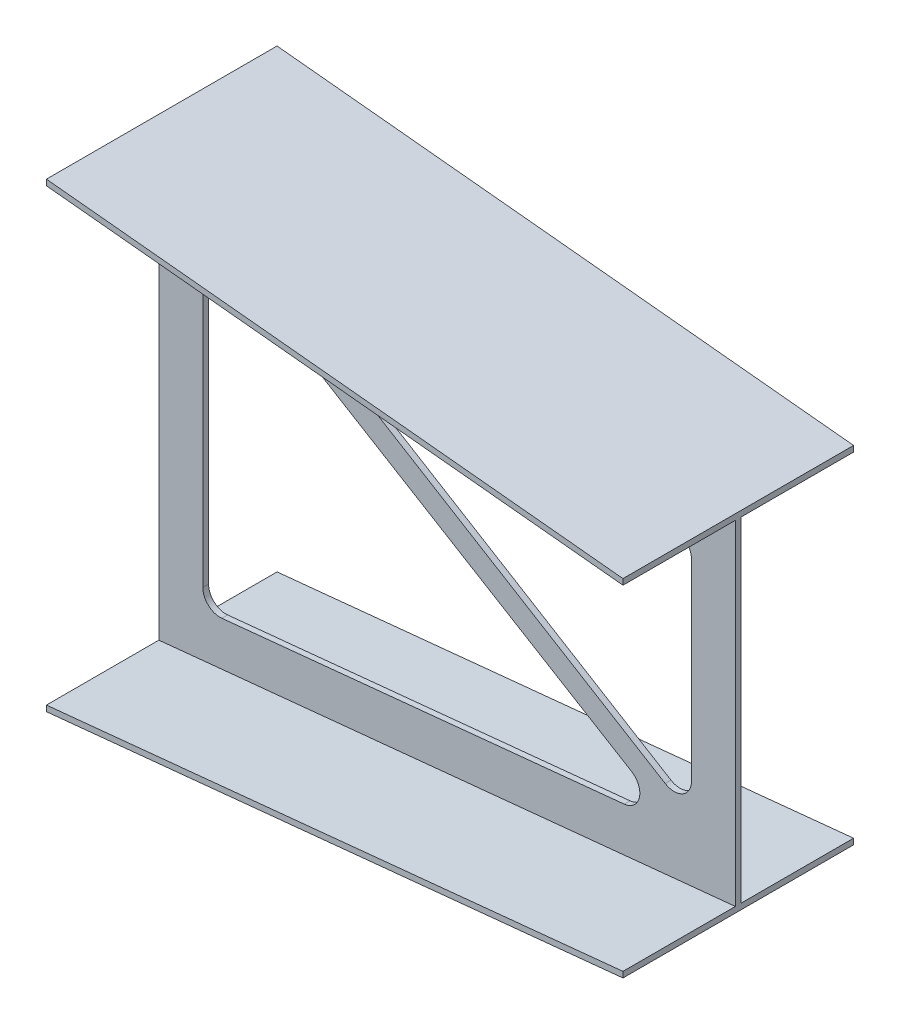
from build123d import *

# Parameters (mm, degrees)
CUT_EXTRUDE1_DEPTH = 206.0000001


with BuildPart() as part:
    # Sketch1 → Loft4 section 0
    with BuildSketch(Plane(origin=(0, 0, 0), x_dir=(0, 0, -1), z_dir=(1, 0, 0))):
        Polygon((-205, 400), (195, 400), (195, 390), (0, 390), (0, -390), (195, -390), (195, -400), (-205, -400), (-205, -390), (-10, -390), (-10, 390), (-205, 390), align=None)
    # Sketch4 → Loft4 section 1
    with BuildSketch(Plane(origin=(1000, 0, -1000), x_dir=(0, 0, 1), z_dir=(-1, 0, 0))):
        Polygon((805, 300), (1205, 300), (1205, 290), (1010, 290), (1010, -290), (1205, -290), (1205, -300), (805, -300), (805, -290), (1000, -290), (1000, 290), (805, 290), align=None)
    loft()

    # Sketch6 → Cut-Extrude1 (cut, through all)
    with BuildSketch(Plane.XY.offset(10)):
        with BuildLine():
            Line((221.736940013, 233.917126741), (878.189220239, -166.0970465))
            ThreePointArc((878.189220239, -166.0970465), (908.491436403, -166.635109102), (923.8, -140.478624315))
            Line((923.8, -140.478624315), (923.8, 193.890320904))
            ThreePointArc((923.8, 193.890320904), (916.043576007, 214.020480527), (896.785111571, 223.74143661))
            Line((896.785111571, 223.74143661), (240.332831344, 289.386664633))
            ThreePointArc((240.332831344, 289.386664633), (208.903576567, 269.071308844), (221.736940013, 233.917126741))
        make_face()
        with BuildLine():
            Line((121.727711267, 245.109508509), (819.804188988, -177.17381685))
            ThreePointArc((819.804188988, -177.17381685), (833.539047237, -209.453423865), (807.261589291, -232.693788838))
            Line((807.261589291, -232.693788838), (109.185111571, -302.50143661))
            ThreePointArc((109.185111571, -302.50143661), (86.069840377, -294.89389691), (76.2, -272.650320904))
            Line((76.2, -272.650320904), (76.2, 219.440652228))
            ThreePointArc((76.2, 219.440652228), (91.466218035, 245.573307451), (121.727711267, 245.109508509))
        make_face()
    extrude(amount=-CUT_EXTRUDE1_DEPTH, mode=Mode.SUBTRACT)


solid = part.part
